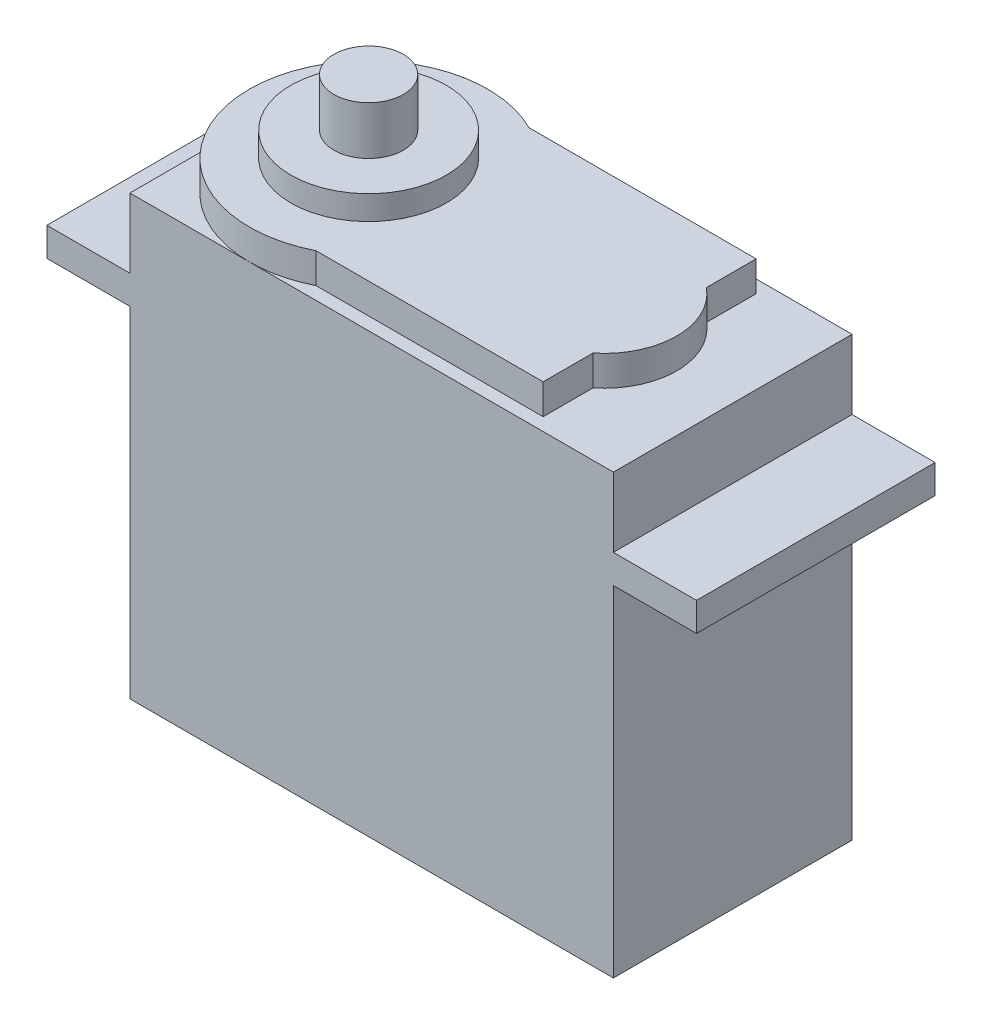
from build123d import *

# Parameters (mm, degrees)
BOSS_EXTRUDE1_DEPTH = 20.066
BOSS_EXTRUDE2_DEPTH = 2.54
SKETCH3_R           = 6.5405
BOSS_EXTRUDE3_DEPTH = 2.032
SKETCH4_R           = 2.921
BOSS_EXTRUDE4_DEPTH = 4.064


with BuildPart() as part:
    # Sketch1 → Boss-Extrude1 (new body)
    with BuildSketch(Plane.XY):
        Polygon((0, 0), (40.64, 0), (40.64, 28.575), (47.625, 28.575), (47.625, 30.988), (40.64, 30.988), (40.64, 36.83), (0, 36.83), (0, 30.988), (-6.985, 30.988), (-6.985, 28.575), (0, 28.575), align=None)
    extrude(amount=BOSS_EXTRUDE1_DEPTH)

    # Sketch2 → Boss-Extrude2 (add)
    with BuildSketch(Plane(origin=(0, 36.83, 0), x_dir=(1, 0, 0), z_dir=(0, 1, 0))):
        with BuildLine():
            Line((14.560242732, -1.0795), (33.655, -1.0795))
            Line((33.655, -1.0795), (33.655, -5.2705))
            ThreePointArc((33.655, -5.2705), (35.941, -10.033), (33.655, -14.7955))
            Line((33.655, -14.7955), (33.655, -18.9865))
            Line((33.655, -18.9865), (14.560242732, -18.9865))
            ThreePointArc((14.560242732, -18.9865), (0, -10.033), (14.560242732, -1.0795))
        make_face()
    extrude(amount=BOSS_EXTRUDE2_DEPTH)

    # Sketch3 → Boss-Extrude3 (add)
    with BuildSketch(Plane(origin=(0, 39.37, 0), x_dir=(1, 0, 0), z_dir=(0, 1, 0))):
        with Locations((10.033, -10.033)):
            Circle(SKETCH3_R)
    extrude(amount=BOSS_EXTRUDE3_DEPTH)

    # Sketch4 → Boss-Extrude4 (add)
    with BuildSketch(Plane(origin=(0, 41.402, 0), x_dir=(1, 0, 0), z_dir=(0, 1, 0))):
        with Locations((10.033, -10.033)):
            Circle(SKETCH4_R)
    extrude(amount=BOSS_EXTRUDE4_DEPTH)


solid = part.part
